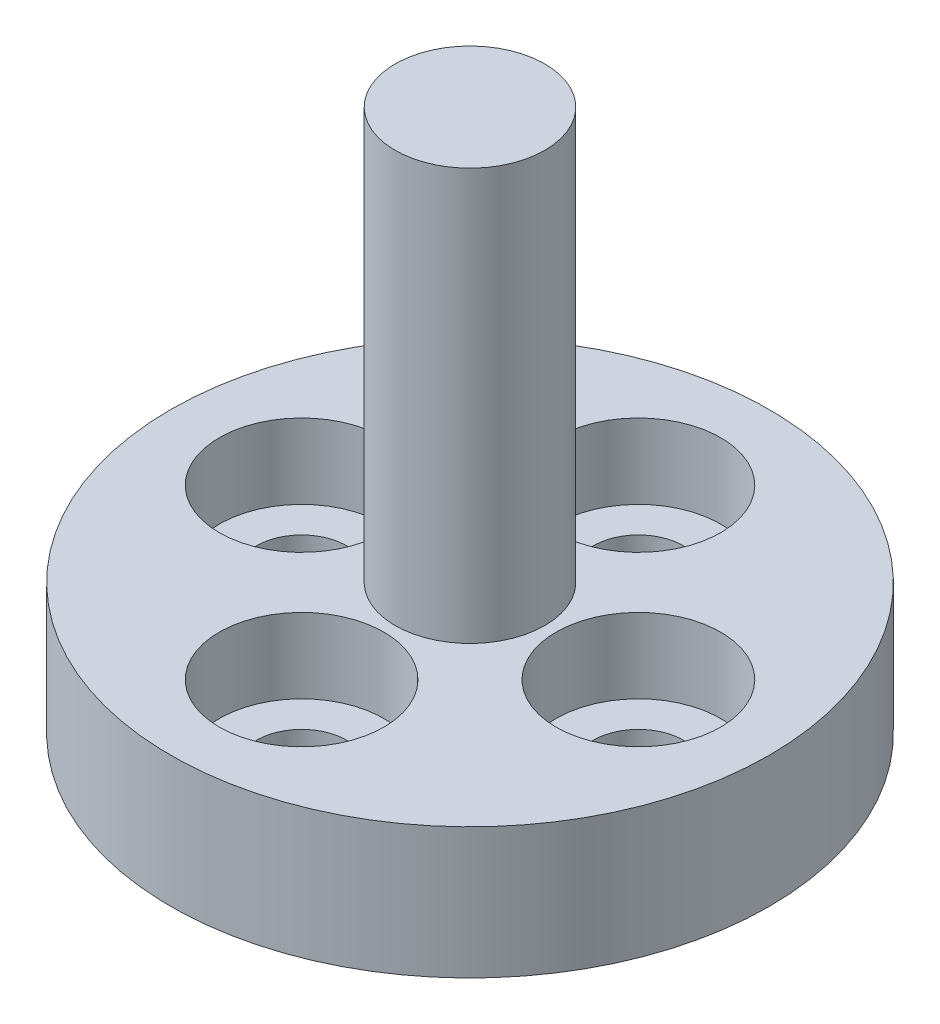
from build123d import *

# Parameters (mm, degrees)
CBORE_FOR_M2_SHCS1_D           = 2.4
CBORE_FOR_M2_SHCS1_CBORE_D     = 4.4
CBORE_FOR_M2_SHCS1_CBORE_DEPTH = 2
SKETCH8_R                      = 1
CUT_EXTRUDE1_DEPTH             = 14.06
FILLET1_R                      = 1


with BuildPart() as part:
    # Sketch3 → Revolve1 (revolve)
    with BuildSketch(Plane.XY):
        Polygon((0, 0), (0, 14.5), (2, 14.5), (2, 3.5), (8, 3.5), (8, 0), align=None)
    revolve(axis=Axis((0, 0, 0), (0, 1, 0)))

    # CBORE for M2 SHCS1 (through all)
    with Locations(Plane(origin=(0, 3.5, 0), x_dir=(1, 0, 0), z_dir=(0, 1, 0))):
        with Locations((-4.5, 0), (0, 4.5), (4.5, 0), (0, -4.5)):
            CounterBoreHole(CBORE_FOR_M2_SHCS1_D / 2, CBORE_FOR_M2_SHCS1_CBORE_D / 2, CBORE_FOR_M2_SHCS1_CBORE_DEPTH)

    # Sketch8 → Cut-Extrude1 (cut)
    with BuildSketch(Plane.XZ):
        Circle(SKETCH8_R)
    extrude(amount=-CUT_EXTRUDE1_DEPTH, mode=Mode.SUBTRACT)

    # Fillet1
    fillet1_edges = [part.edges().sort_by_distance(p)[0] for p in [
        (-1, 14.06, 0),
        (-1, 0, 0),
    ]]
    fillet(fillet1_edges, radius=FILLET1_R)


solid = part.part
